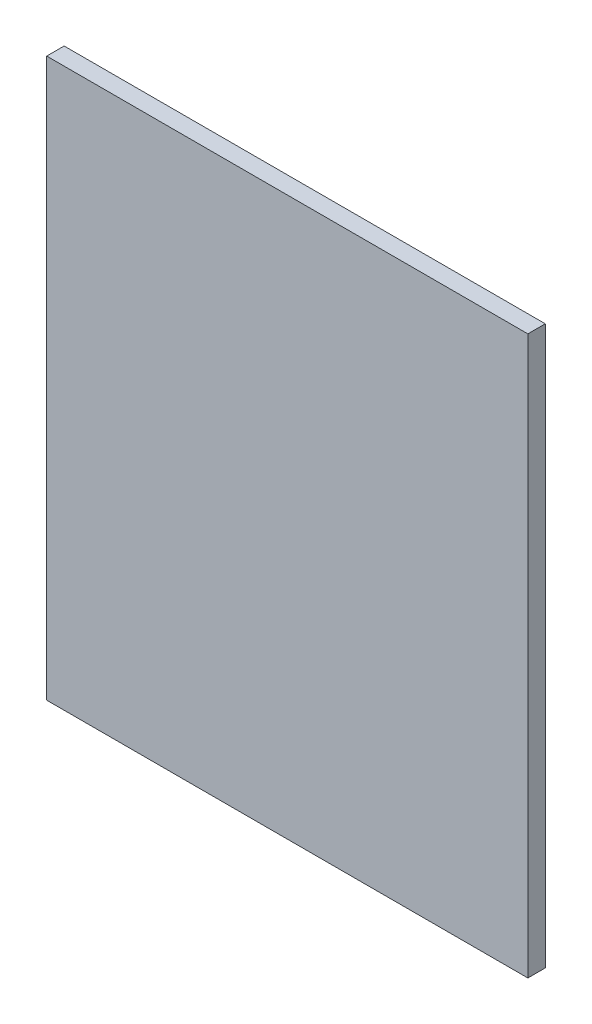
from build123d import *

# Parameters (mm, degrees)
SKETCH1_W           = 87.63
SKETCH1_H           = 101.6
BOSS_EXTRUDE1_DEPTH = 3.175


with BuildPart() as part:
    # Sketch1 → Boss-Extrude1 (new body)
    with BuildSketch(Plane.XY):
        Rectangle(SKETCH1_W, SKETCH1_H)
    extrude(amount=BOSS_EXTRUDE1_DEPTH)


solid = part.part
